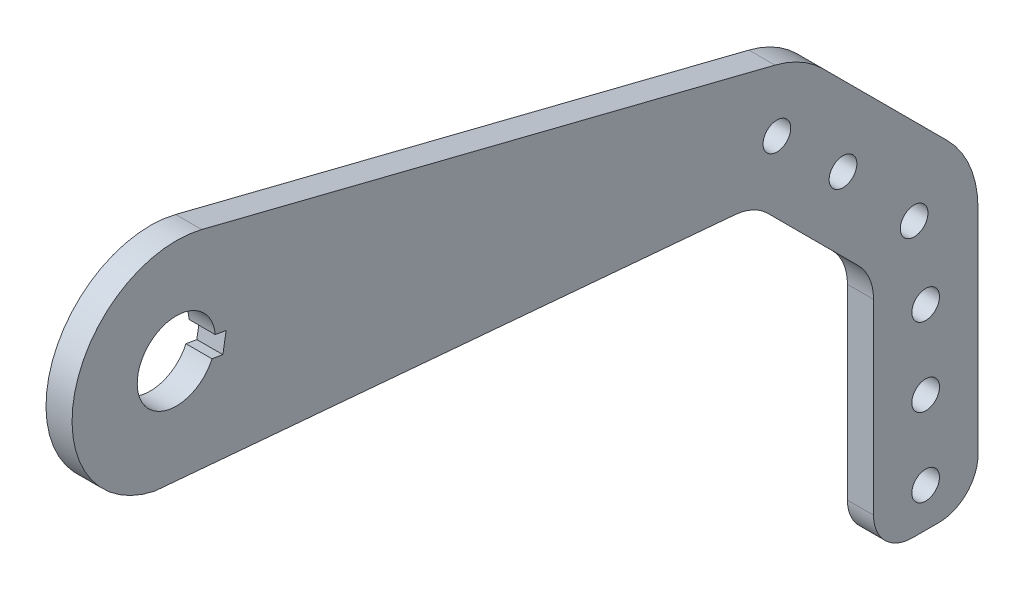
from build123d import *

# Parameters (mm, degrees)
SKETCH1_R                   = 19.05
BOSS_EXTRUDE1_DEPTH         = 12.7
FILLET1_R                   = 25.4
FILLET2_R                   = 50.8
F_1_2_CLEARANCE_HOLE1_D     = 13.49248
F_1_2_CLEARANCE_HOLE1_DEPTH = 38.1
F_1_2_CLEARANCE_HOLE1_TIP   = 4.053549943
FILLET3_R                   = 19.05
CUT_EXTRUDE1_DEPTH          = 13.7
F_1_2_CLEARANCE_HOLE2_D     = 13.49248


with BuildPart() as part:
    # Sketch1 → Boss-Extrude1 (new body)
    with BuildSketch(Plane(origin=(0, 0, 0), x_dir=(0, 0, -1), z_dir=(1, 0, 0))):
        with BuildLine():
            Line((390.630407277, -109.766978243), (305.29908743, -24.435658396))
            Line((305.29908743, -24.435658396), (12.395871839, 49.264412727))
            ThreePointArc((12.395871839, 49.264412727), (-49.470959365, 11.544010545), (-10.688712274, -49.662777107))
            Line((-10.688712274, -49.662777107), (281.610658396, -75.235658396))
            Line((281.610658396, -75.235658396), (339.725, -133.35))
            Line((339.725, -133.35), (339.725, -254))
            Line((339.725, -254), (390.630407277, -254))
            Line((390.630407277, -254), (390.630407277, -109.766978243))
        make_face()
        Circle(SKETCH1_R, mode=Mode.SUBTRACT)
    extrude(amount=BOSS_EXTRUDE1_DEPTH)

    # Fillet1
    fillet1_edges = [part.edges().sort_by_distance(p)[0] for p in [
        (6.35, -133.35, -339.725),
        (6.35, -75.235658396, -281.610658396),
    ]]
    fillet(fillet1_edges, radius=FILLET1_R)

    # Fillet2
    fillet2_edges = [part.edges().sort_by_distance(p)[0] for p in [
        (6.35, -24.435658396, -305.29908743),
        (6.35, -109.766978243, -390.630407277),
    ]]
    fillet(fillet2_edges, radius=FILLET2_R)

    # 1/2 Clearance Hole1
    with Locations(Plane(origin=(12.7, 0, 0), x_dir=(0, 0, -1), z_dir=(1, 0, 0))):
        with Locations((365.125, -234.95), (365.125, -196.85), (365.125, -158.75), (359.5071206, -120.65), (324.846024484, -82.55)):
            Hole(F_1_2_CLEARANCE_HOLE1_D / 2, depth=F_1_2_CLEARANCE_HOLE1_DEPTH)
            with Locations((0, 0, -(F_1_2_CLEARANCE_HOLE1_DEPTH + F_1_2_CLEARANCE_HOLE1_TIP / 2))):  # 118° drill point
                Cone(0, F_1_2_CLEARANCE_HOLE1_D / 2, F_1_2_CLEARANCE_HOLE1_TIP, mode=Mode.SUBTRACT)

    # Fillet3
    fillet3_edges = [part.edges().sort_by_distance(p)[0] for p in [
        (6.35, -254, -390.630407277),
        (6.35, -254, -339.725),
    ]]
    fillet(fillet3_edges, radius=FILLET3_R)

    # Sketch4 → Cut-Extrude1 (cut, through all)
    with BuildSketch(Plane(origin=(12.7, 0, 0), x_dir=(0, 0, -1), z_dir=(1, 0, 0))):
        Polygon((23.478806451, -3.972505995), (24.27330765, 0.723255295), (14.88178507, 2.312257693), (13.292782672, -7.079264887), (22.684305252, -8.668267285), align=None)
    extrude(amount=-CUT_EXTRUDE1_DEPTH, mode=Mode.SUBTRACT)

    # 1/2 Clearance Hole2 (through all)
    with Locations(Plane(origin=(12.7, 0, 0), x_dir=(0, 0, -1), z_dir=(1, 0, 0))):
        with Locations((292.641331438, -51.40137192)):
            Hole(F_1_2_CLEARANCE_HOLE2_D / 2)


solid = part.part
